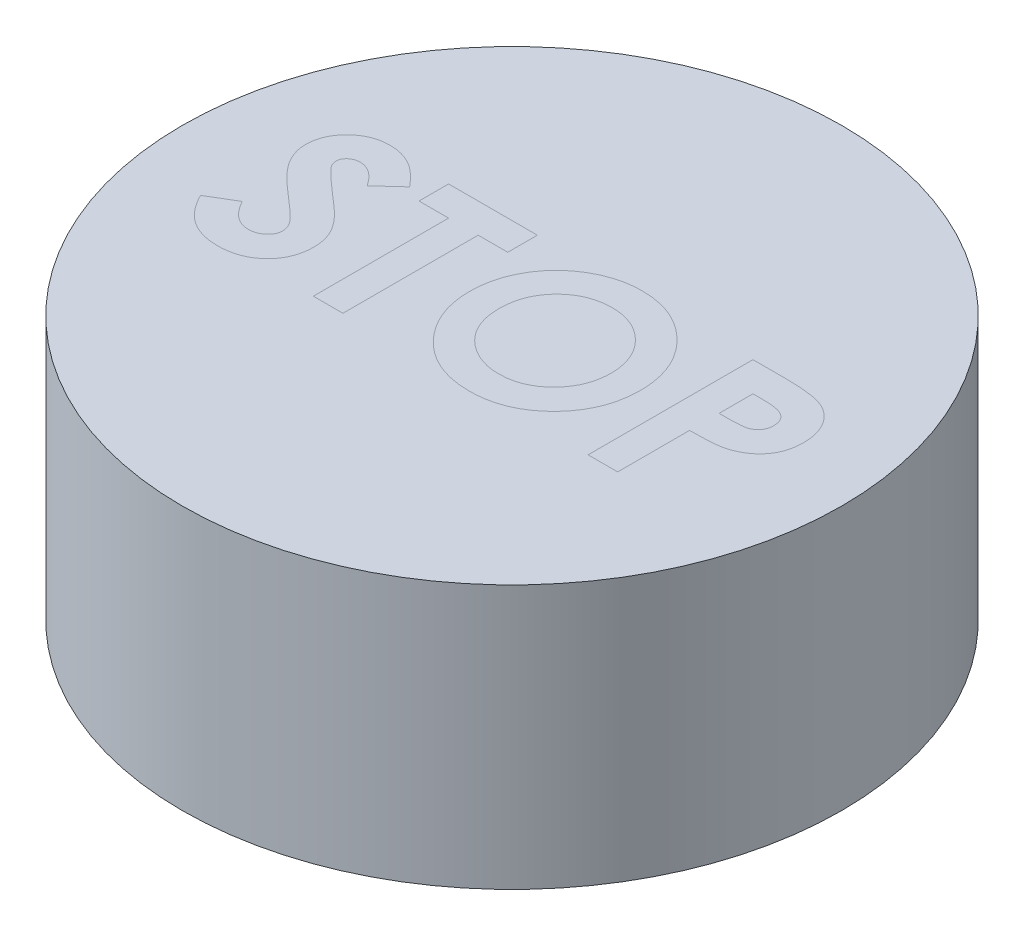
from build123d import *

# Parameters (mm, degrees)
SKETCH3_R               = 10
SKETCH3_W               = 2.15
SKETCH3_H               = 3.15
BOSS_EXTRUDE1_DEPTH     = 3
SKETCH4_R               = 10
BOSS_EXTRUDE2_DEPTH     = 5
CUT_EXTRUDE1_START      = 5
CUT_EXTRUDE1_DEPTH      = 16
CUT_EXTRUDE1_DEPTH_BACK = 0.4
BOSS_EXTRUDE3_START     = 5
BOSS_EXTRUDE3_DEPTH     = 0.4
BOSS_EXTRUDE3_2_DEPTH   = 0.4
BOSS_EXTRUDE3_3_DEPTH   = 0.4
BOSS_EXTRUDE3_4_DEPTH   = 0.4


with BuildPart() as part:
    # Sketch3 → Boss-Extrude1 (new body)
    with BuildSketch(Plane(origin=(0, 0, 0), x_dir=(1, 0, 0), z_dir=(0, 1, 0))):
        with Locations(Location((0, 0, 0), (0, 0, 270))):
            Circle(SKETCH3_R)
        Rectangle(SKETCH3_W, SKETCH3_H, mode=Mode.SUBTRACT)
    extrude(amount=-BOSS_EXTRUDE1_DEPTH)

    # Sketch4 → Boss-Extrude2 (add)
    with BuildSketch(Plane(origin=(0, 0, 0), x_dir=(1, 0, 0), z_dir=(0, 1, 0))):
        with Locations(Location((0, 0, 0), (0, 0, 270))):
            Circle(SKETCH4_R)
    extrude(amount=BOSS_EXTRUDE2_DEPTH)

    # Sketch5 → Cut-Extrude1 (cut, two sides)
    with BuildSketch(Plane(origin=(0, 0, 0), x_dir=(1, 0, 0), z_dir=(0, 1, 0)).offset(CUT_EXTRUDE1_START)) as cut_extrude1_sk:
        with BuildLine():
            Line((-4.935897436, 1.83193109), (-5.606971154, 1.217948718))
            add(Edge.make_bspline(
                [(-5.606971154, 1.217948718), (-5.635717074, 1.258497827), (-5.690905233, 1.336346463), (-5.780359482, 1.44058762), (-5.869409799, 1.529513085), (-5.958881182, 1.602751368), (-6.04956667, 1.659857492), (-6.141308847, 1.700289258), (-6.2335876, 1.725992116), (-6.295584678, 1.72919274), (-6.326121795, 1.730769231)],
                knots=[0, 0, 0, 0, 1.299362458, 2.494594718, 3.587462134, 4.587049575, 5.512617175, 6.380583204, 7.202344345, 8, 8, 8, 8], degree=3))
            add(Edge.make_bspline(
                [(-6.326121795, 1.730769231), (-6.354605941, 1.729770294), (-6.409601345, 1.727841609), (-6.488001372, 1.708670625), (-6.557606033, 1.675584321), (-6.618347396, 1.632321196), (-6.666463518, 1.580199161), (-6.704880509, 1.525536547), (-6.726512504, 1.465201384), (-6.7293597, 1.423760759), (-6.730769231, 1.403245192)],
                knots=[0, 0, 0, 0, 1.185010067, 2.2879431, 3.333075148, 4.379039566, 5.372662701, 6.27520591, 7.14612461, 8, 8, 8, 8], degree=3))
            add(Edge.make_bspline(
                [(-6.730769231, 1.403245192), (-6.729885949, 1.382433782), (-6.728107143, 1.340522492), (-6.710926294, 1.279096278), (-6.68502985, 1.219075717), (-6.66028474, 1.182538345), (-6.647636218, 1.163862179)],
                knots=[0, 0, 0, 0, 0.967525499, 1.948461899, 2.951351359, 4, 4, 4, 4], degree=3))
            add(Edge.make_bspline(
                [(-6.647636218, 1.163862179), (-6.636137343, 1.149345391), (-6.609668451, 1.115929662), (-6.559197695, 1.063004356), (-6.495817025, 0.998166224), (-6.41708742, 0.923644859), (-6.326277162, 0.83676018), (-6.219177078, 0.740927659), (-6.098869976, 0.633179473), (-6.013358475, 0.558147537), (-5.968549679, 0.518830128)],
                knots=[0, 0, 0, 0, 0.473873513, 1.090794244, 1.870441696, 2.795289791, 3.865433203, 5.087734844, 6.473946851, 8, 8, 8, 8], degree=3))
            add(Edge.make_bspline(
                [(-5.968549679, 0.518830128), (-5.926490179, 0.482429752), (-5.846669985, 0.4133494), (-5.733101699, 0.315300932), (-5.633294091, 0.227089116), (-5.545793191, 0.150037823), (-5.471925427, 0.083338608), (-5.411380259, 0.02667265), (-5.363418231, -0.01885687), (-5.336154626, -0.046356727), (-5.324519231, -0.058092949)],
                knots=[0, 0, 0, 0, 1.543621617, 2.929473131, 4.163658386, 5.240097082, 6.164993805, 6.925417477, 7.541396219, 8, 8, 8, 8], degree=3))
            add(Edge.make_bspline(
                [(-5.324519231, -0.058092949), (-5.280376967, -0.105864332), (-5.195520035, -0.197697706), (-5.085235936, -0.340010556), (-4.994468556, -0.478936916), (-4.924249189, -0.61709091), (-4.8712167, -0.756465826), (-4.833828092, -0.900479826), (-4.811435806, -1.050637766), (-4.808949739, -1.15310223), (-4.807692308, -1.204927885)],
                knots=[0, 0, 0, 0, 1.206664779, 2.319633467, 3.337109185, 4.282041471, 5.190008762, 6.099243693, 7.03861361, 8, 8, 8, 8], degree=3))
            add(Edge.make_bspline(
                [(-4.807692308, -1.204927885), (-4.808587315, -1.25542563), (-4.810343353, -1.354504084), (-4.83185145, -1.499490645), (-4.862520733, -1.638249076), (-4.909940826, -1.769269489), (-4.967736154, -1.894702545), (-5.040190944, -2.012594396), (-5.125279161, -2.124138155), (-5.222803323, -2.22733984), (-5.330676625, -2.320988217), (-5.446380995, -2.404356214), (-5.571047846, -2.473187115), (-5.703612046, -2.529864452), (-5.844002635, -2.573518094), (-5.992052366, -2.605782205), (-6.147987691, -2.625146615), (-6.254618514, -2.627170935), (-6.309094551, -2.628205128)],
                knots=[0, 0, 0, 0, 1.043214005, 2.046824704, 3.02475056, 3.976699089, 4.921714032, 5.875962561, 6.831408892, 7.817874052, 8.806269674, 9.781291748, 10.760897367, 11.74438705, 12.757449933, 13.795994037, 14.874007457, 16, 16, 16, 16], degree=3))
            add(Edge.make_bspline(
                [(-6.309094551, -2.628205128), (-6.351857777, -2.62744648), (-6.436553488, -2.625943922), (-6.561382161, -2.613676784), (-6.681918357, -2.593878928), (-6.798026301, -2.565502686), (-6.91022908, -2.52954614), (-7.018531303, -2.485626596), (-7.122185323, -2.433063317), (-7.221975436, -2.372937215), (-7.317416538, -2.30312289), (-7.409715445, -2.225047673), (-7.497955356, -2.137510733), (-7.582560071, -2.040719092), (-7.662988263, -1.934398657), (-7.741872637, -1.82003014), (-7.815707334, -1.695491014), (-7.86131831, -1.60812581), (-7.884615385, -1.563501603)],
                knots=[0, 0, 0, 0, 1.016823716, 2.013894106, 2.979844003, 3.91962641, 4.853723003, 5.779685073, 6.695824784, 7.614987388, 8.547259901, 9.504950863, 10.487499108, 11.500346958, 12.559593716, 13.656357062, 14.802919212, 16, 16, 16, 16], degree=3))
            Line((-7.884615385, -1.563501603), (-7.095352564, -1.08974359))
            add(Edge.make_bspline(
                [(-7.095352564, -1.08974359), (-7.066211406, -1.140397895), (-7.010345316, -1.237506528), (-6.915675002, -1.367984284), (-6.8186901, -1.479716883), (-6.717148403, -1.570729446), (-6.612284622, -1.642238927), (-6.50359224, -1.693344564), (-6.390994891, -1.724978895), (-6.314298693, -1.728842177), (-6.276041667, -1.730769231)],
                knots=[0, 0, 0, 0, 1.283663364, 2.460892379, 3.537111102, 4.529833553, 5.449777664, 6.316464042, 7.160231139, 8, 8, 8, 8], degree=3))
            add(Edge.make_bspline(
                [(-6.276041667, -1.730769231), (-6.237128794, -1.729195494), (-6.161632153, -1.726142216), (-6.05387036, -1.697940006), (-5.955070267, -1.653660467), (-5.869668197, -1.590479671), (-5.797355109, -1.517559429), (-5.743983899, -1.436432327), (-5.710455744, -1.34865476), (-5.706911006, -1.287678688), (-5.705128205, -1.257011218)],
                knots=[0, 0, 0, 0, 1.13588714, 2.203786484, 3.234766741, 4.283437687, 5.291419208, 6.222934724, 7.106237994, 8, 8, 8, 8], degree=3))
            add(Edge.make_bspline(
                [(-5.705128205, -1.257011218), (-5.706774548, -1.228480128), (-5.710118937, -1.170521949), (-5.734752674, -1.084347457), (-5.773262719, -0.998212155), (-5.818822817, -0.92756165), (-5.865185922, -0.868407897), (-5.909519507, -0.817153847), (-5.963506086, -0.760527094), (-6.027008773, -0.698456406), (-6.099188532, -0.63039536), (-6.180106165, -0.55635062), (-6.270688264, -0.476974432), (-6.33471187, -0.422904157), (-6.368189103, -0.39463141)],
                knots=[0, 0, 0, 0, 0.916159276, 1.861089862, 2.860218735, 3.940849679, 4.552606315, 5.27541173, 6.11797699, 7.06649574, 8.129236253, 9.306560635, 10.591630461, 12, 12, 12, 12], degree=3))
            add(Edge.make_bspline(
                [(-6.368189103, -0.39463141), (-6.431830655, -0.340784555), (-6.553978056, -0.23743614), (-6.726587831, -0.084793786), (-6.882124693, 0.057864481), (-7.01924526, 0.192302228), (-7.139696659, 0.316036702), (-7.242663141, 0.430072921), (-7.327013572, 0.535290519), (-7.415774213, 0.659913723), (-7.500114569, 0.81177566), (-7.573008569, 0.994483175), (-7.620299121, 1.177167507), (-7.625597369, 1.299811705), (-7.628205128, 1.360176282)],
                knots=[0, 0, 0, 0, 1.345494975, 2.582412109, 3.71882943, 4.751509156, 5.681369928, 6.505683931, 7.230279997, 7.856715994, 8.973648664, 10.023341002, 11.027102913, 12, 12, 12, 12], degree=3))
            add(Edge.make_bspline(
                [(-7.628205128, 1.360176282), (-7.627120565, 1.4029836), (-7.624983858, 1.487318614), (-7.605924105, 1.611320964), (-7.577438577, 1.730972813), (-7.536069413, 1.845837616), (-7.482377234, 1.955771501), (-7.417170167, 2.06131264), (-7.339435672, 2.161489655), (-7.251834143, 2.256236138), (-7.155319687, 2.342823641), (-7.052181725, 2.419245789), (-6.943004028, 2.483793046), (-6.828454489, 2.537339683), (-6.707823293, 2.578326232), (-6.581999124, 2.60737954), (-6.45080151, 2.624659522), (-6.361563725, 2.627008535), (-6.316105769, 2.628205128)],
                knots=[0, 0, 0, 0, 1.010766082, 1.991317756, 2.957454644, 3.913069143, 4.869106762, 5.843196583, 6.838735724, 7.860187025, 8.887984031, 9.89767229, 10.887916223, 11.879572884, 12.879850636, 13.892031539, 14.926195476, 16, 16, 16, 16], degree=3))
            add(Edge.make_bspline(
                [(-6.316105769, 2.628205128), (-6.257194508, 2.626050029), (-6.139837011, 2.621756841), (-5.966320567, 2.58818552), (-5.79683696, 2.535391081), (-5.660263892, 2.471700398), (-5.551595252, 2.410003203), (-5.46831089, 2.353200198), (-5.383564569, 2.288129303), (-5.296672862, 2.214585463), (-5.209250352, 2.131183014), (-5.118811198, 2.039907417), (-5.026587745, 1.939969839), (-4.966657123, 1.868574896), (-4.935897436, 1.83193109)],
                knots=[0, 0, 0, 0, 1.282922637, 2.555718331, 3.837320111, 5.142675274, 5.830281639, 6.55870424, 7.337177975, 8.157850921, 9.037902056, 9.96903443, 10.957596896, 12, 12, 12, 12], degree=3))
        make_face()
        Polygon((-4.423076923, 2.5), (-1.730769231, 2.5), (-1.730769231, 1.602564103), (-2.628205128, 1.602564103), (-2.628205128, -2.5), (-3.525641026, -2.5), (-3.525641026, 1.602564103), (-4.423076923, 1.602564103), align=None)
        with BuildLine():
            add(Edge.make_bspline(
                [(1.32411859, 2.628205128), (1.411049718, 2.625954326), (1.582671453, 2.621510732), (1.835065095, 2.584469907), (2.078293036, 2.524117193), (2.31224529, 2.440222556), (2.536336066, 2.330513702), (2.751355809, 2.19810095), (2.956534327, 2.040485087), (3.149769116, 1.861343033), (3.328352912, 1.666533871), (3.483095875, 1.456787173), (3.615054997, 1.237537688), (3.724423071, 1.00819793), (3.807727216, 0.767179612), (3.86618518, 0.515711609), (3.903741525, 0.25386546), (3.908061083, 0.075583923), (3.91025641, -0.015024038)],
                knots=[0, 0, 0, 0, 1.014329547, 2.002516266, 2.970391464, 3.935626869, 4.897733899, 5.877609409, 6.878433252, 7.912639331, 8.949961323, 9.958554974, 10.949718813, 11.932905612, 12.9188844, 13.919928257, 14.942845884, 16, 16, 16, 16], degree=3))
            add(Edge.make_bspline(
                [(3.91025641, -0.015024038), (3.907918482, -0.104611058), (3.903311519, -0.281145153), (3.867718394, -0.540578287), (3.808275991, -0.789352544), (3.72638475, -1.028031031), (3.619000199, -1.255457672), (3.489614424, -1.473084555), (3.334813178, -1.678892048), (3.160242672, -1.872769709), (2.968055694, -2.048755288), (2.764499175, -2.203842276), (2.550513014, -2.335257136), (2.326410417, -2.442939676), (2.091710807, -2.526508129), (1.846993922, -2.585471745), (1.592274904, -2.621305125), (1.41905362, -2.625881996), (1.331129808, -2.628205128)],
                knots=[0, 0, 0, 0, 1.051557043, 2.072126891, 3.067553643, 4.050577992, 5.02905126, 6.015227836, 7.017913613, 8.04756643, 9.074058332, 10.072836633, 11.047628519, 12.017157415, 12.98668631, 13.966869689, 14.968021931, 16, 16, 16, 16], degree=3))
            add(Edge.make_bspline(
                [(1.331129808, -2.628205128), (1.239172043, -2.626121164), (1.058487605, -2.62202646), (0.794055121, -2.583087689), (0.540705952, -2.524432299), (0.300568378, -2.436892275), (0.071196802, -2.327459884), (-0.145723515, -2.192687334), (-0.350119674, -2.032797346), (-0.540819224, -1.851884763), (-0.713593479, -1.653926717), (-0.866100649, -1.444801596), (-0.99474383, -1.226106933), (-1.099527728, -0.997740373), (-1.182135145, -0.761121159), (-1.240405291, -0.514808211), (-1.274826857, -0.259392278), (-1.279621582, -0.085908671), (-1.282051282, 0.002003205)],
                knots=[0, 0, 0, 0, 1.067978421, 2.098431617, 3.099715153, 4.085208694, 5.062210972, 6.048429807, 7.046490867, 8.072918869, 9.098532598, 10.095778865, 11.076610158, 12.041847152, 13.011192615, 13.984257998, 14.978533688, 16, 16, 16, 16], degree=3))
            add(Edge.make_bspline(
                [(-1.282051282, 0.002003205), (-1.281288702, 0.061145713), (-1.279773198, 0.178681849), (-1.261517357, 0.352864403), (-1.235234193, 0.523647147), (-1.196362642, 0.690349168), (-1.149143643, 0.854146472), (-1.087964759, 1.013514392), (-1.018326633, 1.170155417), (-0.936961039, 1.322219418), (-0.846490365, 1.468307282), (-0.747778806, 1.607729885), (-0.640578152, 1.738801405), (-0.525233732, 1.862383189), (-0.401348053, 1.977662926), (-0.270550703, 2.086272561), (-0.130304976, 2.185327035), (0.01631959, 2.277245457), (0.168496358, 2.360365692), (0.325605832, 2.43111515), (0.484411247, 2.492899447), (0.647034027, 2.541662346), (0.811731381, 2.581379217), (0.980262766, 2.607644665), (1.151105597, 2.625900001), (1.266310727, 2.627434929), (1.32411859, 2.628205128)],
                knots=[0, 0, 0, 0, 1.034744296, 2.056386356, 3.06226378, 4.057406941, 5.050368692, 6.043467995, 7.042652155, 8.049140477, 9.059438543, 10.048523776, 11.036952808, 12.020949711, 13.004946614, 13.997082645, 14.994316842, 16.007702937, 17.024872941, 18.026463647, 19.021641123, 20.005082605, 20.995858141, 21.984425357, 22.988620895, 24, 24, 24, 24], degree=3))
        make_face()
        with BuildLine():
            add(Edge.make_bspline(
                [(1.310096154, 1.730769231), (1.251591516, 1.72919942), (1.136126773, 1.726101242), (0.966761023, 1.702497313), (0.804163922, 1.664799157), (0.64923681, 1.610193838), (0.501308219, 1.540695126), (0.360115917, 1.456545858), (0.227615127, 1.354853496), (0.102039078, 1.241077451), (-0.011398218, 1.114304789), (-0.111623648, 0.978446322), (-0.19549619, 0.833728931), (-0.265739969, 0.681497006), (-0.318617966, 0.52003874), (-0.356281379, 0.350618853), (-0.380083249, 0.172945426), (-0.383083505, 0.051825682), (-0.384615385, -0.010016026)],
                knots=[0, 0, 0, 0, 1.033739768, 2.040188636, 3.016340934, 3.979330865, 4.937572243, 5.900995986, 6.878200029, 7.884839167, 8.891893314, 9.879764717, 10.863503415, 11.843163062, 12.837761627, 13.859916423, 14.907309254, 16, 16, 16, 16], degree=3))
            add(Edge.make_bspline(
                [(-0.384615385, -0.010016026), (-0.382584346, -0.078550549), (-0.378603846, -0.212866859), (-0.350596564, -0.408803874), (-0.302678892, -0.593846937), (-0.233486706, -0.767091032), (-0.147670243, -0.930459903), (-0.041099815, -1.081951234), (0.08449864, -1.222472083), (0.181258672, -1.304514008), (0.23036859, -1.346153846)],
                knots=[0, 0, 0, 0, 1.078454662, 2.113592447, 3.107694534, 4.079536787, 5.043276885, 6.005368276, 6.987637804, 8, 8, 8, 8], degree=3))
            add(Edge.make_bspline(
                [(0.23036859, -1.346153846), (0.270598988, -1.37691576), (0.350153386, -1.437746516), (0.477139525, -1.515713608), (0.607910245, -1.582539184), (0.743452372, -1.636533459), (0.88347965, -1.679004449), (1.027972877, -1.708746184), (1.176727317, -1.727411695), (1.277322041, -1.729642577), (1.328125, -1.730769231)],
                knots=[0, 0, 0, 0, 1.023928204, 2.024787132, 3.009472467, 3.9914905, 4.972207045, 5.96565515, 6.972602802, 8, 8, 8, 8], degree=3))
            add(Edge.make_bspline(
                [(1.328125, -1.730769231), (1.385623649, -1.72918611), (1.498754049, -1.726071269), (1.664966964, -1.702757918), (1.824203985, -1.663303311), (1.977453669, -1.609177009), (2.124274112, -1.538805681), (2.263947762, -1.452046366), (2.396719506, -1.349964358), (2.522135573, -1.234694184), (2.636771786, -1.107422125), (2.736788067, -0.970839003), (2.823327336, -0.827954152), (2.892110395, -0.676745254), (2.947077482, -0.518639651), (2.984287596, -0.352937125), (3.008290538, -0.180320767), (3.011291639, -0.062849235), (3.012820513, -0.003004808)],
                knots=[0, 0, 0, 0, 1.026359118, 2.019393844, 2.989460624, 3.950973911, 4.916101784, 5.890408035, 6.881132271, 7.902007068, 8.92769091, 9.933912415, 10.920395702, 11.90457117, 12.894218921, 13.903490204, 14.931958862, 16, 16, 16, 16], degree=3))
            add(Edge.make_bspline(
                [(3.012820513, -0.003004808), (3.01123874, 0.056495498), (3.008125261, 0.173612775), (2.984770877, 0.345785338), (2.94556648, 0.510756335), (2.891277643, 0.668795182), (2.821953673, 0.820056815), (2.73622755, 0.96400931), (2.634400079, 1.100513498), (2.518814811, 1.228639157), (2.39300735, 1.346378431), (2.257940471, 1.448554717), (2.117393496, 1.537342661), (1.968141591, 1.606895552), (1.813238327, 1.662308192), (1.651738473, 1.703114855), (1.483030341, 1.725935423), (1.368254711, 1.729143599), (1.310096154, 1.730769231)],
                knots=[0, 0, 0, 0, 1.055025985, 2.07665775, 3.074803781, 4.057872707, 5.035505728, 6.020516407, 7.023567878, 8.050795229, 9.077271434, 10.074415901, 11.050397877, 12.019801805, 12.988065821, 13.964604439, 14.968634123, 16, 16, 16, 16], degree=3))
        make_face(mode=Mode.SUBTRACT)
        with BuildLine():
            Line((4.807692308, 2.5), (5.809294872, 2.5))
            add(Edge.make_bspline(
                [(5.809294872, 2.5), (5.874738284, 2.499707061), (6.000992344, 2.499141921), (6.183061086, 2.492288847), (6.351028414, 2.480007719), (6.50485574, 2.464830188), (6.644479813, 2.443551879), (6.770075483, 2.419157965), (6.881668816, 2.389439077), (6.980518192, 2.35416317), (7.069232314, 2.312574253), (7.153184486, 2.268279087), (7.23047738, 2.21541437), (7.305012202, 2.159677635), (7.372527668, 2.095744374), (7.437235796, 2.027869438), (7.496396021, 1.953360962), (7.550282469, 1.873120852), (7.599165781, 1.788631603), (7.641873512, 1.699742171), (7.676515632, 1.6063119), (7.705576063, 1.508945176), (7.728917685, 1.407646244), (7.744454611, 1.301792105), (7.755008073, 1.192121874), (7.75593927, 1.117480245), (7.756410256, 1.079727564)],
                knots=[0, 0, 0, 0, 1.698747864, 3.27724071, 4.728299578, 6.070144658, 7.288476769, 8.393259625, 9.389771311, 10.283485332, 11.113357557, 11.931608583, 12.74405601, 13.541433047, 14.344816069, 15.154114104, 15.974336324, 16.810834471, 17.661136416, 18.50621059, 19.367396281, 20.244825668, 21.142564693, 22.063065223, 23.020325768, 24, 24, 24, 24], degree=3))
            add(Edge.make_bspline(
                [(7.756410256, 1.079727564), (7.755728798, 1.037962672), (7.754389649, 0.955889528), (7.741261668, 0.835580367), (7.71883493, 0.720876474), (7.689524356, 0.610810532), (7.648652845, 0.507193369), (7.601959063, 0.407552647), (7.5445109, 0.314681987), (7.47886719, 0.227419688), (7.40717677, 0.145056267), (7.327737713, 0.069969812), (7.24206416, 0.001648461), (7.150652045, -0.060623799), (7.053158181, -0.116721351), (6.949652913, -0.16716949), (6.839429448, -0.210354726), (6.762673144, -0.232940255), (6.723758013, -0.244391026)],
                knots=[0, 0, 0, 0, 1.102006807, 2.165578795, 3.188629044, 4.184801286, 5.166646146, 6.124351954, 7.085497154, 8.042432466, 9.003981491, 9.963833307, 10.922997304, 11.89326795, 12.880200226, 13.889073926, 14.929769137, 16, 16, 16, 16], degree=3))
            add(Edge.make_bspline(
                [(6.723758013, -0.244391026), (6.698126269, -0.250768245), (6.642599657, -0.264583356), (6.550718366, -0.278609161), (6.444834825, -0.291505026), (6.324606643, -0.302587461), (6.189964506, -0.310120935), (6.041038783, -0.316004243), (5.877761983, -0.320282015), (5.764225753, -0.320433809), (5.705128205, -0.320512821)],
                knots=[0, 0, 0, 0, 0.618981996, 1.340914327, 2.176866532, 3.120127938, 4.170906482, 5.338178032, 6.614476169, 8, 8, 8, 8], degree=3))
            Line((5.705128205, -0.320512821), (5.705128205, -2.5))
            Line((5.705128205, -2.5), (4.807692308, -2.5))
            Line((4.807692308, -2.5), (4.807692308, 2.5))
        make_face()
        with BuildLine():
            Line((5.705128205, 0.576923077), (6.022636218, 0.576923077))
            add(Edge.make_bspline(
                [(6.022636218, 0.576923077), (6.080411814, 0.577289419), (6.186719768, 0.577963494), (6.331898893, 0.587711009), (6.44856763, 0.602597435), (6.540738099, 0.623948011), (6.613515414, 0.656350337), (6.676281293, 0.693833728), (6.730117189, 0.741230446), (6.776731151, 0.795389306), (6.813997609, 0.85762055), (6.839839956, 0.926910865), (6.856626637, 1.001804385), (6.858177043, 1.053925318), (6.858974359, 1.080729167)],
                knots=[0, 0, 0, 0, 1.8619151, 3.425951444, 4.686033666, 5.651700536, 6.461346321, 7.243864085, 7.999046032, 8.762387399, 9.539336099, 10.322741239, 11.137448474, 12, 12, 12, 12], degree=3))
            add(Edge.make_bspline(
                [(6.858974359, 1.080729167), (6.858185245, 1.10414734), (6.856654173, 1.149584228), (6.845406504, 1.215160926), (6.827480956, 1.276291938), (6.801507526, 1.332338828), (6.76793003, 1.383206367), (6.726992269, 1.428874514), (6.679219552, 1.470321291), (6.642336222, 1.492259704), (6.623597756, 1.503405449)],
                knots=[0, 0, 0, 0, 1.102301479, 2.1387299, 3.123554645, 4.094223062, 5.036071848, 5.982632524, 6.975082478, 8, 8, 8, 8], degree=3))
            add(Edge.make_bspline(
                [(6.623597756, 1.503405449), (6.607725194, 1.511432659), (6.574119728, 1.528427907), (6.51688636, 1.548186125), (6.450839927, 1.564854359), (6.375534542, 1.578688832), (6.29127062, 1.58942582), (6.198063193, 1.59763693), (6.0957751, 1.600938937), (6.024639851, 1.602007439), (5.987580128, 1.602564103)],
                knots=[0, 0, 0, 0, 0.656809284, 1.390599849, 2.23162475, 3.173112763, 4.218524733, 5.370385145, 6.63003504, 8, 8, 8, 8], degree=3))
            Line((5.987580128, 1.602564103), (5.705128205, 1.602564103))
            Line((5.705128205, 1.602564103), (5.705128205, 0.576923077))
        make_face(mode=Mode.SUBTRACT)
    extrude(amount=CUT_EXTRUDE1_DEPTH, mode=Mode.SUBTRACT)
    extrude(cut_extrude1_sk.sketch, amount=-CUT_EXTRUDE1_DEPTH_BACK, mode=Mode.SUBTRACT)


with BuildPart() as body_2:
    # Sketch5_2 → Boss-Extrude3 (new body)
    with BuildSketch(Plane(origin=(0, 0, 0), x_dir=(1, 0, 0), z_dir=(0, 1, 0)).offset(BOSS_EXTRUDE3_START)):
        with BuildLine():
            Line((-4.935897436, 1.83193109), (-5.606971154, 1.217948718))
            add(Edge.make_bspline(
                [(-5.606971154, 1.217948718), (-5.635717074, 1.258497827), (-5.690905233, 1.336346463), (-5.780359482, 1.44058762), (-5.869409799, 1.529513085), (-5.958881182, 1.602751368), (-6.04956667, 1.659857492), (-6.141308847, 1.700289258), (-6.2335876, 1.725992116), (-6.295584678, 1.72919274), (-6.326121795, 1.730769231)],
                knots=[0, 0, 0, 0, 1.299362458, 2.494594718, 3.587462134, 4.587049575, 5.512617175, 6.380583204, 7.202344345, 8, 8, 8, 8], degree=3))
            add(Edge.make_bspline(
                [(-6.326121795, 1.730769231), (-6.354605941, 1.729770294), (-6.409601345, 1.727841609), (-6.488001372, 1.708670625), (-6.557606033, 1.675584321), (-6.618347396, 1.632321196), (-6.666463518, 1.580199161), (-6.704880509, 1.525536547), (-6.726512504, 1.465201384), (-6.7293597, 1.423760759), (-6.730769231, 1.403245192)],
                knots=[0, 0, 0, 0, 1.185010067, 2.2879431, 3.333075148, 4.379039566, 5.372662701, 6.27520591, 7.14612461, 8, 8, 8, 8], degree=3))
            add(Edge.make_bspline(
                [(-6.730769231, 1.403245192), (-6.729885949, 1.382433782), (-6.728107143, 1.340522492), (-6.710926294, 1.279096278), (-6.68502985, 1.219075717), (-6.66028474, 1.182538345), (-6.647636218, 1.163862179)],
                knots=[0, 0, 0, 0, 0.967525499, 1.948461899, 2.951351359, 4, 4, 4, 4], degree=3))
            add(Edge.make_bspline(
                [(-6.647636218, 1.163862179), (-6.636137343, 1.149345391), (-6.609668451, 1.115929662), (-6.559197695, 1.063004356), (-6.495817025, 0.998166224), (-6.41708742, 0.923644859), (-6.326277162, 0.83676018), (-6.219177078, 0.740927659), (-6.098869976, 0.633179473), (-6.013358475, 0.558147537), (-5.968549679, 0.518830128)],
                knots=[0, 0, 0, 0, 0.473873513, 1.090794244, 1.870441696, 2.795289791, 3.865433203, 5.087734844, 6.473946851, 8, 8, 8, 8], degree=3))
            add(Edge.make_bspline(
                [(-5.968549679, 0.518830128), (-5.926490179, 0.482429752), (-5.846669985, 0.4133494), (-5.733101699, 0.315300932), (-5.633294091, 0.227089116), (-5.545793191, 0.150037823), (-5.471925427, 0.083338608), (-5.411380259, 0.02667265), (-5.363418231, -0.01885687), (-5.336154626, -0.046356727), (-5.324519231, -0.058092949)],
                knots=[0, 0, 0, 0, 1.543621617, 2.929473131, 4.163658386, 5.240097082, 6.164993805, 6.925417477, 7.541396219, 8, 8, 8, 8], degree=3))
            add(Edge.make_bspline(
                [(-5.324519231, -0.058092949), (-5.280376967, -0.105864332), (-5.195520035, -0.197697706), (-5.085235936, -0.340010556), (-4.994468556, -0.478936916), (-4.924249189, -0.61709091), (-4.8712167, -0.756465826), (-4.833828092, -0.900479826), (-4.811435806, -1.050637766), (-4.808949739, -1.15310223), (-4.807692308, -1.204927885)],
                knots=[0, 0, 0, 0, 1.206664779, 2.319633467, 3.337109185, 4.282041471, 5.190008762, 6.099243693, 7.03861361, 8, 8, 8, 8], degree=3))
            add(Edge.make_bspline(
                [(-4.807692308, -1.204927885), (-4.808587315, -1.25542563), (-4.810343353, -1.354504084), (-4.83185145, -1.499490645), (-4.862520733, -1.638249076), (-4.909940826, -1.769269489), (-4.967736154, -1.894702545), (-5.040190944, -2.012594396), (-5.125279161, -2.124138155), (-5.222803323, -2.22733984), (-5.330676625, -2.320988217), (-5.446380995, -2.404356214), (-5.571047846, -2.473187115), (-5.703612046, -2.529864452), (-5.844002635, -2.573518094), (-5.992052366, -2.605782205), (-6.147987691, -2.625146615), (-6.254618514, -2.627170935), (-6.309094551, -2.628205128)],
                knots=[0, 0, 0, 0, 1.043214005, 2.046824704, 3.02475056, 3.976699089, 4.921714032, 5.875962561, 6.831408892, 7.817874052, 8.806269674, 9.781291748, 10.760897367, 11.74438705, 12.757449933, 13.795994037, 14.874007457, 16, 16, 16, 16], degree=3))
            add(Edge.make_bspline(
                [(-6.309094551, -2.628205128), (-6.351857777, -2.62744648), (-6.436553488, -2.625943922), (-6.561382161, -2.613676784), (-6.681918357, -2.593878928), (-6.798026301, -2.565502686), (-6.91022908, -2.52954614), (-7.018531303, -2.485626596), (-7.122185323, -2.433063317), (-7.221975436, -2.372937215), (-7.317416538, -2.30312289), (-7.409715445, -2.225047673), (-7.497955356, -2.137510733), (-7.582560071, -2.040719092), (-7.662988263, -1.934398657), (-7.741872637, -1.82003014), (-7.815707334, -1.695491014), (-7.86131831, -1.60812581), (-7.884615385, -1.563501603)],
                knots=[0, 0, 0, 0, 1.016823716, 2.013894106, 2.979844003, 3.91962641, 4.853723003, 5.779685073, 6.695824784, 7.614987388, 8.547259901, 9.504950863, 10.487499108, 11.500346958, 12.559593716, 13.656357062, 14.802919212, 16, 16, 16, 16], degree=3))
            Line((-7.884615385, -1.563501603), (-7.095352564, -1.08974359))
            add(Edge.make_bspline(
                [(-7.095352564, -1.08974359), (-7.066211406, -1.140397895), (-7.010345316, -1.237506528), (-6.915675002, -1.367984284), (-6.8186901, -1.479716883), (-6.717148403, -1.570729446), (-6.612284622, -1.642238927), (-6.50359224, -1.693344564), (-6.390994891, -1.724978895), (-6.314298693, -1.728842177), (-6.276041667, -1.730769231)],
                knots=[0, 0, 0, 0, 1.283663364, 2.460892379, 3.537111102, 4.529833553, 5.449777664, 6.316464042, 7.160231139, 8, 8, 8, 8], degree=3))
            add(Edge.make_bspline(
                [(-6.276041667, -1.730769231), (-6.237128794, -1.729195494), (-6.161632153, -1.726142216), (-6.05387036, -1.697940006), (-5.955070267, -1.653660467), (-5.869668197, -1.590479671), (-5.797355109, -1.517559429), (-5.743983899, -1.436432327), (-5.710455744, -1.34865476), (-5.706911006, -1.287678688), (-5.705128205, -1.257011218)],
                knots=[0, 0, 0, 0, 1.13588714, 2.203786484, 3.234766741, 4.283437687, 5.291419208, 6.222934724, 7.106237994, 8, 8, 8, 8], degree=3))
            add(Edge.make_bspline(
                [(-5.705128205, -1.257011218), (-5.706774548, -1.228480128), (-5.710118937, -1.170521949), (-5.734752674, -1.084347457), (-5.773262719, -0.998212155), (-5.818822817, -0.92756165), (-5.865185922, -0.868407897), (-5.909519507, -0.817153847), (-5.963506086, -0.760527094), (-6.027008773, -0.698456406), (-6.099188532, -0.63039536), (-6.180106165, -0.55635062), (-6.270688264, -0.476974432), (-6.33471187, -0.422904157), (-6.368189103, -0.39463141)],
                knots=[0, 0, 0, 0, 0.916159276, 1.861089862, 2.860218735, 3.940849679, 4.552606315, 5.27541173, 6.11797699, 7.06649574, 8.129236253, 9.306560635, 10.591630461, 12, 12, 12, 12], degree=3))
            add(Edge.make_bspline(
                [(-6.368189103, -0.39463141), (-6.431830655, -0.340784555), (-6.553978056, -0.23743614), (-6.726587831, -0.084793786), (-6.882124693, 0.057864481), (-7.01924526, 0.192302228), (-7.139696659, 0.316036702), (-7.242663141, 0.430072921), (-7.327013572, 0.535290519), (-7.415774213, 0.659913723), (-7.500114569, 0.81177566), (-7.573008569, 0.994483175), (-7.620299121, 1.177167507), (-7.625597369, 1.299811705), (-7.628205128, 1.360176282)],
                knots=[0, 0, 0, 0, 1.345494975, 2.582412109, 3.71882943, 4.751509156, 5.681369928, 6.505683931, 7.230279997, 7.856715994, 8.973648664, 10.023341002, 11.027102913, 12, 12, 12, 12], degree=3))
            add(Edge.make_bspline(
                [(-7.628205128, 1.360176282), (-7.627120565, 1.4029836), (-7.624983858, 1.487318614), (-7.605924105, 1.611320964), (-7.577438577, 1.730972813), (-7.536069413, 1.845837616), (-7.482377234, 1.955771501), (-7.417170167, 2.06131264), (-7.339435672, 2.161489655), (-7.251834143, 2.256236138), (-7.155319687, 2.342823641), (-7.052181725, 2.419245789), (-6.943004028, 2.483793046), (-6.828454489, 2.537339683), (-6.707823293, 2.578326232), (-6.581999124, 2.60737954), (-6.45080151, 2.624659522), (-6.361563725, 2.627008535), (-6.316105769, 2.628205128)],
                knots=[0, 0, 0, 0, 1.010766082, 1.991317756, 2.957454644, 3.913069143, 4.869106762, 5.843196583, 6.838735724, 7.860187025, 8.887984031, 9.89767229, 10.887916223, 11.879572884, 12.879850636, 13.892031539, 14.926195476, 16, 16, 16, 16], degree=3))
            add(Edge.make_bspline(
                [(-6.316105769, 2.628205128), (-6.257194508, 2.626050029), (-6.139837011, 2.621756841), (-5.966320567, 2.58818552), (-5.79683696, 2.535391081), (-5.660263892, 2.471700398), (-5.551595252, 2.410003203), (-5.46831089, 2.353200198), (-5.383564569, 2.288129303), (-5.296672862, 2.214585463), (-5.209250352, 2.131183014), (-5.118811198, 2.039907417), (-5.026587745, 1.939969839), (-4.966657123, 1.868574896), (-4.935897436, 1.83193109)],
                knots=[0, 0, 0, 0, 1.282922637, 2.555718331, 3.837320111, 5.142675274, 5.830281639, 6.55870424, 7.337177975, 8.157850921, 9.037902056, 9.96903443, 10.957596896, 12, 12, 12, 12], degree=3))
        make_face()
    extrude(amount=-BOSS_EXTRUDE3_DEPTH)


with BuildPart() as body_3:
    # Sketch5_2 → Boss-Extrude3 2 (new body)
    with BuildSketch(Plane(origin=(0, 0, 0), x_dir=(1, 0, 0), z_dir=(0, 1, 0)).offset(BOSS_EXTRUDE3_START)):
        Polygon((-4.423076923, 2.5), (-1.730769231, 2.5), (-1.730769231, 1.602564103), (-2.628205128, 1.602564103), (-2.628205128, -2.5), (-3.525641026, -2.5), (-3.525641026, 1.602564103), (-4.423076923, 1.602564103), align=None)
    extrude(amount=-BOSS_EXTRUDE3_2_DEPTH)


with BuildPart() as body_4:
    # Sketch5_2 → Boss-Extrude3 3 (new body)
    with BuildSketch(Plane(origin=(0, 0, 0), x_dir=(1, 0, 0), z_dir=(0, 1, 0)).offset(BOSS_EXTRUDE3_START)):
        with BuildLine():
            add(Edge.make_bspline(
                [(1.32411859, 2.628205128), (1.411049718, 2.625954326), (1.582671453, 2.621510732), (1.835065095, 2.584469907), (2.078293036, 2.524117193), (2.31224529, 2.440222556), (2.536336066, 2.330513702), (2.751355809, 2.19810095), (2.956534327, 2.040485087), (3.149769116, 1.861343033), (3.328352912, 1.666533871), (3.483095875, 1.456787173), (3.615054997, 1.237537688), (3.724423071, 1.00819793), (3.807727216, 0.767179612), (3.86618518, 0.515711609), (3.903741525, 0.25386546), (3.908061083, 0.075583923), (3.91025641, -0.015024038)],
                knots=[0, 0, 0, 0, 1.014329547, 2.002516266, 2.970391464, 3.935626869, 4.897733899, 5.877609409, 6.878433252, 7.912639331, 8.949961323, 9.958554974, 10.949718813, 11.932905612, 12.9188844, 13.919928257, 14.942845884, 16, 16, 16, 16], degree=3))
            add(Edge.make_bspline(
                [(3.91025641, -0.015024038), (3.907918482, -0.104611058), (3.903311519, -0.281145153), (3.867718394, -0.540578287), (3.808275991, -0.789352544), (3.72638475, -1.028031031), (3.619000199, -1.255457672), (3.489614424, -1.473084555), (3.334813178, -1.678892048), (3.160242672, -1.872769709), (2.968055694, -2.048755288), (2.764499175, -2.203842276), (2.550513014, -2.335257136), (2.326410417, -2.442939676), (2.091710807, -2.526508129), (1.846993922, -2.585471745), (1.592274904, -2.621305125), (1.41905362, -2.625881996), (1.331129808, -2.628205128)],
                knots=[0, 0, 0, 0, 1.051557043, 2.072126891, 3.067553643, 4.050577992, 5.02905126, 6.015227836, 7.017913613, 8.04756643, 9.074058332, 10.072836633, 11.047628519, 12.017157415, 12.98668631, 13.966869689, 14.968021931, 16, 16, 16, 16], degree=3))
            add(Edge.make_bspline(
                [(1.331129808, -2.628205128), (1.239172043, -2.626121164), (1.058487605, -2.62202646), (0.794055121, -2.583087689), (0.540705952, -2.524432299), (0.300568378, -2.436892275), (0.071196802, -2.327459884), (-0.145723515, -2.192687334), (-0.350119674, -2.032797346), (-0.540819224, -1.851884763), (-0.713593479, -1.653926717), (-0.866100649, -1.444801596), (-0.99474383, -1.226106933), (-1.099527728, -0.997740373), (-1.182135145, -0.761121159), (-1.240405291, -0.514808211), (-1.274826857, -0.259392278), (-1.279621582, -0.085908671), (-1.282051282, 0.002003205)],
                knots=[0, 0, 0, 0, 1.067978421, 2.098431617, 3.099715153, 4.085208694, 5.062210972, 6.048429807, 7.046490867, 8.072918869, 9.098532598, 10.095778865, 11.076610158, 12.041847152, 13.011192615, 13.984257998, 14.978533688, 16, 16, 16, 16], degree=3))
            add(Edge.make_bspline(
                [(-1.282051282, 0.002003205), (-1.281288702, 0.061145713), (-1.279773198, 0.178681849), (-1.261517357, 0.352864403), (-1.235234193, 0.523647147), (-1.196362642, 0.690349168), (-1.149143643, 0.854146472), (-1.087964759, 1.013514392), (-1.018326633, 1.170155417), (-0.936961039, 1.322219418), (-0.846490365, 1.468307282), (-0.747778806, 1.607729885), (-0.640578152, 1.738801405), (-0.525233732, 1.862383189), (-0.401348053, 1.977662926), (-0.270550703, 2.086272561), (-0.130304976, 2.185327035), (0.01631959, 2.277245457), (0.168496358, 2.360365692), (0.325605832, 2.43111515), (0.484411247, 2.492899447), (0.647034027, 2.541662346), (0.811731381, 2.581379217), (0.980262766, 2.607644665), (1.151105597, 2.625900001), (1.266310727, 2.627434929), (1.32411859, 2.628205128)],
                knots=[0, 0, 0, 0, 1.034744296, 2.056386356, 3.06226378, 4.057406941, 5.050368692, 6.043467995, 7.042652155, 8.049140477, 9.059438543, 10.048523776, 11.036952808, 12.020949711, 13.004946614, 13.997082645, 14.994316842, 16.007702937, 17.024872941, 18.026463647, 19.021641123, 20.005082605, 20.995858141, 21.984425357, 22.988620895, 24, 24, 24, 24], degree=3))
        make_face()
        with BuildLine():
            add(Edge.make_bspline(
                [(1.310096154, 1.730769231), (1.251591516, 1.72919942), (1.136126773, 1.726101242), (0.966761023, 1.702497313), (0.804163922, 1.664799157), (0.64923681, 1.610193838), (0.501308219, 1.540695126), (0.360115917, 1.456545858), (0.227615127, 1.354853496), (0.102039078, 1.241077451), (-0.011398218, 1.114304789), (-0.111623648, 0.978446322), (-0.19549619, 0.833728931), (-0.265739969, 0.681497006), (-0.318617966, 0.52003874), (-0.356281379, 0.350618853), (-0.380083249, 0.172945426), (-0.383083505, 0.051825682), (-0.384615385, -0.010016026)],
                knots=[0, 0, 0, 0, 1.033739768, 2.040188636, 3.016340934, 3.979330865, 4.937572243, 5.900995986, 6.878200029, 7.884839167, 8.891893314, 9.879764717, 10.863503415, 11.843163062, 12.837761627, 13.859916423, 14.907309254, 16, 16, 16, 16], degree=3))
            add(Edge.make_bspline(
                [(-0.384615385, -0.010016026), (-0.382584346, -0.078550549), (-0.378603846, -0.212866859), (-0.350596564, -0.408803874), (-0.302678892, -0.593846937), (-0.233486706, -0.767091032), (-0.147670243, -0.930459903), (-0.041099815, -1.081951234), (0.08449864, -1.222472083), (0.181258672, -1.304514008), (0.23036859, -1.346153846)],
                knots=[0, 0, 0, 0, 1.078454662, 2.113592447, 3.107694534, 4.079536787, 5.043276885, 6.005368276, 6.987637804, 8, 8, 8, 8], degree=3))
            add(Edge.make_bspline(
                [(0.23036859, -1.346153846), (0.270598988, -1.37691576), (0.350153386, -1.437746516), (0.477139525, -1.515713608), (0.607910245, -1.582539184), (0.743452372, -1.636533459), (0.88347965, -1.679004449), (1.027972877, -1.708746184), (1.176727317, -1.727411695), (1.277322041, -1.729642577), (1.328125, -1.730769231)],
                knots=[0, 0, 0, 0, 1.023928204, 2.024787132, 3.009472467, 3.9914905, 4.972207045, 5.96565515, 6.972602802, 8, 8, 8, 8], degree=3))
            add(Edge.make_bspline(
                [(1.328125, -1.730769231), (1.385623649, -1.72918611), (1.498754049, -1.726071269), (1.664966964, -1.702757918), (1.824203985, -1.663303311), (1.977453669, -1.609177009), (2.124274112, -1.538805681), (2.263947762, -1.452046366), (2.396719506, -1.349964358), (2.522135573, -1.234694184), (2.636771786, -1.107422125), (2.736788067, -0.970839003), (2.823327336, -0.827954152), (2.892110395, -0.676745254), (2.947077482, -0.518639651), (2.984287596, -0.352937125), (3.008290538, -0.180320767), (3.011291639, -0.062849235), (3.012820513, -0.003004808)],
                knots=[0, 0, 0, 0, 1.026359118, 2.019393844, 2.989460624, 3.950973911, 4.916101784, 5.890408035, 6.881132271, 7.902007068, 8.92769091, 9.933912415, 10.920395702, 11.90457117, 12.894218921, 13.903490204, 14.931958862, 16, 16, 16, 16], degree=3))
            add(Edge.make_bspline(
                [(3.012820513, -0.003004808), (3.01123874, 0.056495498), (3.008125261, 0.173612775), (2.984770877, 0.345785338), (2.94556648, 0.510756335), (2.891277643, 0.668795182), (2.821953673, 0.820056815), (2.73622755, 0.96400931), (2.634400079, 1.100513498), (2.518814811, 1.228639157), (2.39300735, 1.346378431), (2.257940471, 1.448554717), (2.117393496, 1.537342661), (1.968141591, 1.606895552), (1.813238327, 1.662308192), (1.651738473, 1.703114855), (1.483030341, 1.725935423), (1.368254711, 1.729143599), (1.310096154, 1.730769231)],
                knots=[0, 0, 0, 0, 1.055025985, 2.07665775, 3.074803781, 4.057872707, 5.035505728, 6.020516407, 7.023567878, 8.050795229, 9.077271434, 10.074415901, 11.050397877, 12.019801805, 12.988065821, 13.964604439, 14.968634123, 16, 16, 16, 16], degree=3))
        make_face(mode=Mode.SUBTRACT)
    extrude(amount=-BOSS_EXTRUDE3_3_DEPTH)


with BuildPart() as body_5:
    # Sketch5_2 → Boss-Extrude3 4 (new body)
    with BuildSketch(Plane(origin=(0, 0, 0), x_dir=(1, 0, 0), z_dir=(0, 1, 0)).offset(BOSS_EXTRUDE3_START)):
        with BuildLine():
            Line((4.807692308, 2.5), (5.809294872, 2.5))
            add(Edge.make_bspline(
                [(5.809294872, 2.5), (5.874738284, 2.499707061), (6.000992344, 2.499141921), (6.183061086, 2.492288847), (6.351028414, 2.480007719), (6.50485574, 2.464830188), (6.644479813, 2.443551879), (6.770075483, 2.419157965), (6.881668816, 2.389439077), (6.980518192, 2.35416317), (7.069232314, 2.312574253), (7.153184486, 2.268279087), (7.23047738, 2.21541437), (7.305012202, 2.159677635), (7.372527668, 2.095744374), (7.437235796, 2.027869438), (7.496396021, 1.953360962), (7.550282469, 1.873120852), (7.599165781, 1.788631603), (7.641873512, 1.699742171), (7.676515632, 1.6063119), (7.705576063, 1.508945176), (7.728917685, 1.407646244), (7.744454611, 1.301792105), (7.755008073, 1.192121874), (7.75593927, 1.117480245), (7.756410256, 1.079727564)],
                knots=[0, 0, 0, 0, 1.698747864, 3.27724071, 4.728299578, 6.070144658, 7.288476769, 8.393259625, 9.389771311, 10.283485332, 11.113357557, 11.931608583, 12.74405601, 13.541433047, 14.344816069, 15.154114104, 15.974336324, 16.810834471, 17.661136416, 18.50621059, 19.367396281, 20.244825668, 21.142564693, 22.063065223, 23.020325768, 24, 24, 24, 24], degree=3))
            add(Edge.make_bspline(
                [(7.756410256, 1.079727564), (7.755728798, 1.037962672), (7.754389649, 0.955889528), (7.741261668, 0.835580367), (7.71883493, 0.720876474), (7.689524356, 0.610810532), (7.648652845, 0.507193369), (7.601959063, 0.407552647), (7.5445109, 0.314681987), (7.47886719, 0.227419688), (7.40717677, 0.145056267), (7.327737713, 0.069969812), (7.24206416, 0.001648461), (7.150652045, -0.060623799), (7.053158181, -0.116721351), (6.949652913, -0.16716949), (6.839429448, -0.210354726), (6.762673144, -0.232940255), (6.723758013, -0.244391026)],
                knots=[0, 0, 0, 0, 1.102006807, 2.165578795, 3.188629044, 4.184801286, 5.166646146, 6.124351954, 7.085497154, 8.042432466, 9.003981491, 9.963833307, 10.922997304, 11.89326795, 12.880200226, 13.889073926, 14.929769137, 16, 16, 16, 16], degree=3))
            add(Edge.make_bspline(
                [(6.723758013, -0.244391026), (6.698126269, -0.250768245), (6.642599657, -0.264583356), (6.550718366, -0.278609161), (6.444834825, -0.291505026), (6.324606643, -0.302587461), (6.189964506, -0.310120935), (6.041038783, -0.316004243), (5.877761983, -0.320282015), (5.764225753, -0.320433809), (5.705128205, -0.320512821)],
                knots=[0, 0, 0, 0, 0.618981996, 1.340914327, 2.176866532, 3.120127938, 4.170906482, 5.338178032, 6.614476169, 8, 8, 8, 8], degree=3))
            Line((5.705128205, -0.320512821), (5.705128205, -2.5))
            Line((5.705128205, -2.5), (4.807692308, -2.5))
            Line((4.807692308, -2.5), (4.807692308, 2.5))
        make_face()
        with BuildLine():
            Line((5.705128205, 0.576923077), (6.022636218, 0.576923077))
            add(Edge.make_bspline(
                [(6.022636218, 0.576923077), (6.080411814, 0.577289419), (6.186719768, 0.577963494), (6.331898893, 0.587711009), (6.44856763, 0.602597435), (6.540738099, 0.623948011), (6.613515414, 0.656350337), (6.676281293, 0.693833728), (6.730117189, 0.741230446), (6.776731151, 0.795389306), (6.813997609, 0.85762055), (6.839839956, 0.926910865), (6.856626637, 1.001804385), (6.858177043, 1.053925318), (6.858974359, 1.080729167)],
                knots=[0, 0, 0, 0, 1.8619151, 3.425951444, 4.686033666, 5.651700536, 6.461346321, 7.243864085, 7.999046032, 8.762387399, 9.539336099, 10.322741239, 11.137448474, 12, 12, 12, 12], degree=3))
            add(Edge.make_bspline(
                [(6.858974359, 1.080729167), (6.858185245, 1.10414734), (6.856654173, 1.149584228), (6.845406504, 1.215160926), (6.827480956, 1.276291938), (6.801507526, 1.332338828), (6.76793003, 1.383206367), (6.726992269, 1.428874514), (6.679219552, 1.470321291), (6.642336222, 1.492259704), (6.623597756, 1.503405449)],
                knots=[0, 0, 0, 0, 1.102301479, 2.1387299, 3.123554645, 4.094223062, 5.036071848, 5.982632524, 6.975082478, 8, 8, 8, 8], degree=3))
            add(Edge.make_bspline(
                [(6.623597756, 1.503405449), (6.607725194, 1.511432659), (6.574119728, 1.528427907), (6.51688636, 1.548186125), (6.450839927, 1.564854359), (6.375534542, 1.578688832), (6.29127062, 1.58942582), (6.198063193, 1.59763693), (6.0957751, 1.600938937), (6.024639851, 1.602007439), (5.987580128, 1.602564103)],
                knots=[0, 0, 0, 0, 0.656809284, 1.390599849, 2.23162475, 3.173112763, 4.218524733, 5.370385145, 6.63003504, 8, 8, 8, 8], degree=3))
            Line((5.987580128, 1.602564103), (5.705128205, 1.602564103))
            Line((5.705128205, 1.602564103), (5.705128205, 0.576923077))
        make_face(mode=Mode.SUBTRACT)
    extrude(amount=-BOSS_EXTRUDE3_4_DEPTH)


solid = Compound([part.part, body_2.part, body_3.part, body_4.part, body_5.part])
